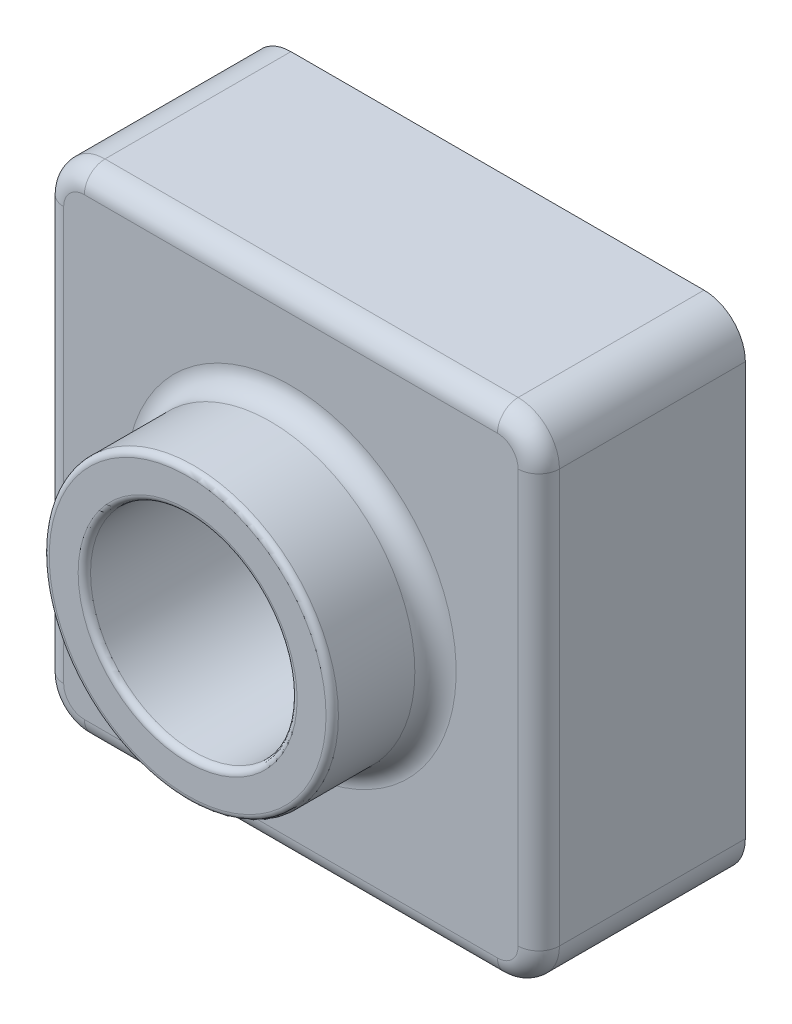
from build123d import *

# Parameters (mm, degrees)
SKETCH1_W           = 120
SKETCH1_H           = 120
BOSS_EXTRUDE1_DEPTH = 50
SKETCH2_R           = 35
BOSS_EXTRUDE2_DEPTH = 25
SKETCH6_R           = 25
CUT_EXTRUDE1_DEPTH  = 76
FILLET3_R           = 10
FILLET4_R           = 1.5
FILLET5_R           = 5
SHELL1_T            = -2


with BuildPart() as part:
    # Sketch1 → Boss-Extrude1 (new body)
    with BuildSketch(Plane.XY):
        with Locations((60, 60)):
            Rectangle(SKETCH1_W, SKETCH1_H)
    extrude(amount=BOSS_EXTRUDE1_DEPTH)

    # Sketch2 → Boss-Extrude2 (add)
    with BuildSketch(Plane.XY.offset(50)):
        with Locations((60, 60)):
            Circle(SKETCH2_R)
    extrude(amount=BOSS_EXTRUDE2_DEPTH)

    # Sketch6 → Cut-Extrude1 (cut, through all)
    with BuildSketch(Plane.XY.offset(75)):
        with Locations((60, 60)):
            Circle(SKETCH6_R)
    extrude(amount=-CUT_EXTRUDE1_DEPTH, mode=Mode.SUBTRACT)

    # Fillet3
    fillet3_edges = [part.edges().sort_by_distance(p)[0] for p in [
        (0, 120, 25),
        (120, 120, 25),
        (120, 0, 25),
        (0, 0, 25),
    ]]
    fillet(fillet3_edges, radius=FILLET3_R)

    # Fillet4
    fillet4_edges = [part.edges().sort_by_distance(p)[0] for p in [
        (25, 60, 75),
        (35, 60, 75),
    ]]
    fillet(fillet4_edges, radius=FILLET4_R)

    # Fillet5
    fillet5_edges = [part.edges().sort_by_distance(p)[0] for p in [
        (25, 60, 50),
        (120, 60, 50),
        (60, 0, 50),
        (0, 60, 50),
        (60, 120, 50),
        (117.071067812, 117.071067812, 50),
        (2.928932188, 117.071067812, 50),
        (2.928932188, 2.928932188, 50),
        (117.071067812, 2.928932188, 50),
    ]]
    fillet(fillet5_edges, radius=FILLET5_R)

    # Shell1
    shell1_openings = [part.faces().sort_by_distance(p)[0] for p in [
        (85, 60, 0),
    ]]
    offset(amount=SHELL1_T, openings=shell1_openings, kind=Kind.INTERSECTION)


solid = part.part
